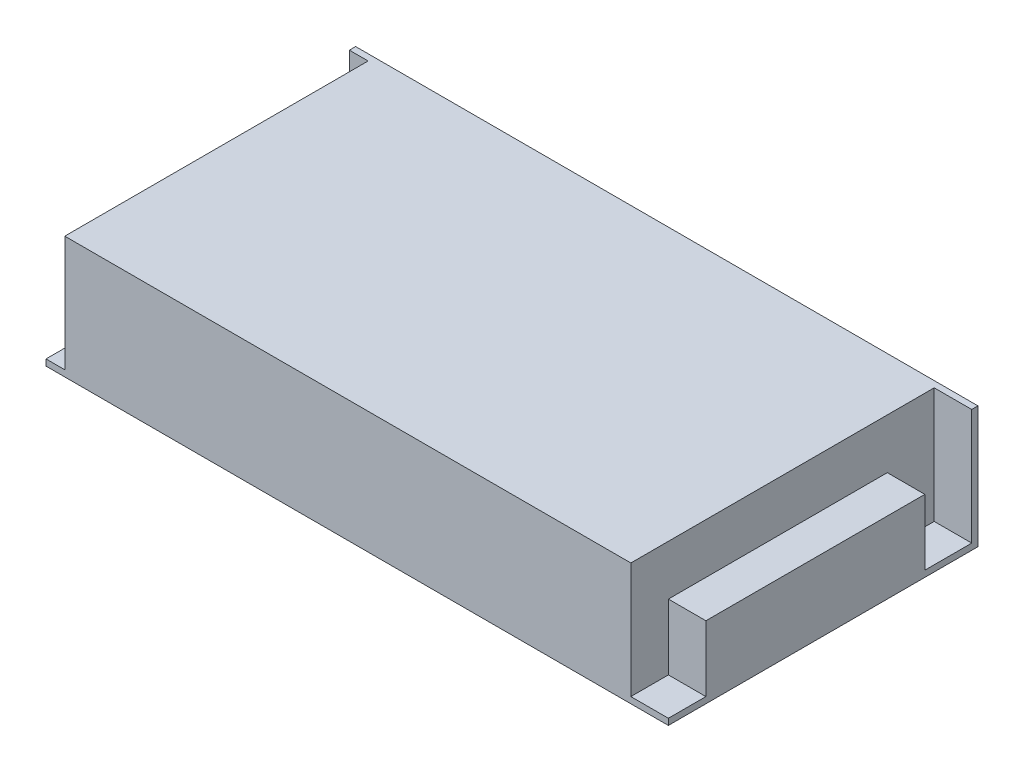
from build123d import *

# Parameters (mm, degrees)
SKETCH_1_W          = 199
SKETCH_1_H          = 99
EXTRUDE_1_DEPTH     = 39
SKETCH_2_W          = 6
SKETCH_2_H          = 97
SKETCH_2_W_2        = 12
CUT_EXTRUDE_1_DEPTH = 37
SKETCH_3_W          = 70
SKETCH_3_H          = 23
EXTRUDE_2_DEPTH     = 12


with BuildPart() as part:
    # Эскиз1 → Бобышка-Вытянуть1 (new body)
    with BuildSketch(Plane(origin=(0, 0, 0), x_dir=(1, 0, 0), z_dir=(0, 1, 0))):
        with Locations((99.5, 49.5)):
            Rectangle(SKETCH_1_W, SKETCH_1_H)
    extrude(amount=EXTRUDE_1_DEPTH)

    # Эскиз2 → Вырез-Вытянуть1 (cut)
    with BuildSketch(Plane(origin=(0, 39, 0), x_dir=(1, 0, 0), z_dir=(0, 1, 0))):
        with Locations((3, 48.5)):
            Rectangle(SKETCH_2_W, SKETCH_2_H)
        with Locations((193, 48.5)):
            Rectangle(SKETCH_2_W_2, SKETCH_2_H)
    extrude(amount=-CUT_EXTRUDE_1_DEPTH, mode=Mode.SUBTRACT)

    # Эскиз3 → Бобышка-Вытянуть2 (add)
    with BuildSketch(Plane(origin=(187, 0, 0), x_dir=(0, 0, -1), z_dir=(1, 0, 0))):
        with Locations((47, 11.5)):
            Rectangle(SKETCH_3_W, SKETCH_3_H)
    extrude(amount=EXTRUDE_2_DEPTH)


solid = part.part
